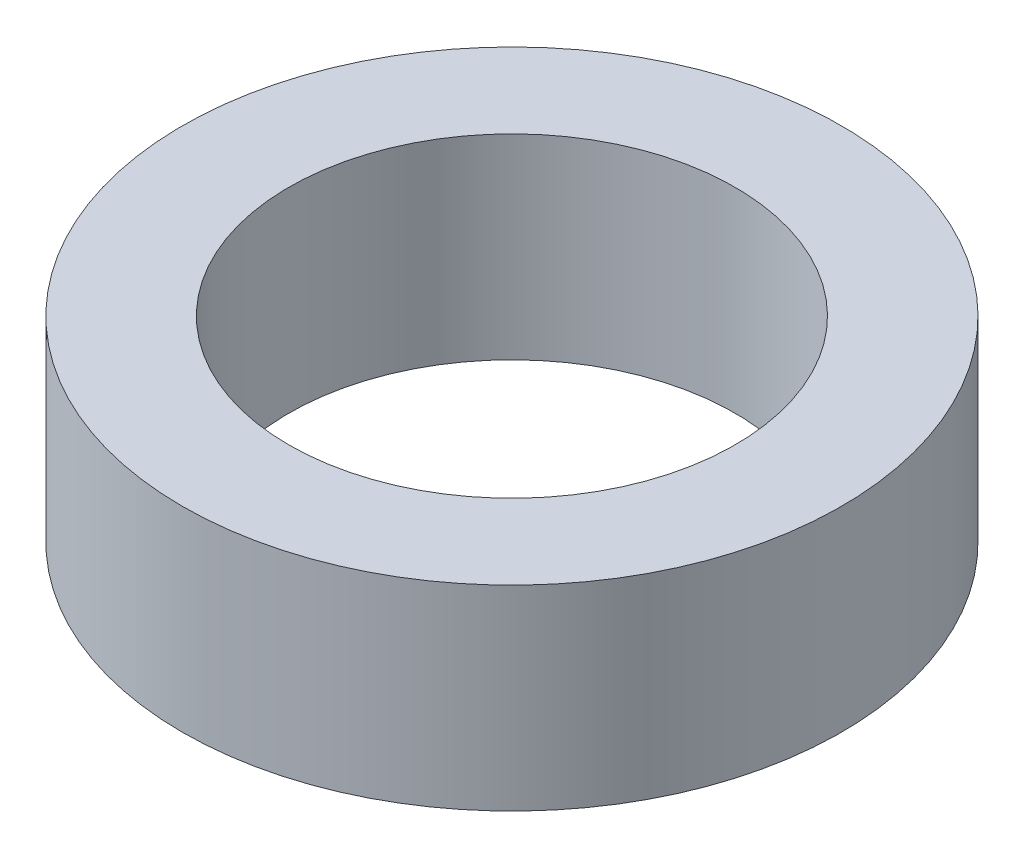
from build123d import *

# Parameters (mm, degrees)
SKETCH1_R           = 9.6
SKETCH1_R_2         = 6.5
BOSS_EXTRUDE1_DEPTH = 5.7


with BuildPart() as part:
    # Sketch1 → Boss-Extrude1 (new body)
    with BuildSketch(Plane(origin=(0, 0, 0), x_dir=(1, 0, 0), z_dir=(0, 1, 0))):
        Circle(SKETCH1_R)
        Circle(SKETCH1_R_2, mode=Mode.SUBTRACT)
    extrude(amount=BOSS_EXTRUDE1_DEPTH)


solid = part.part
